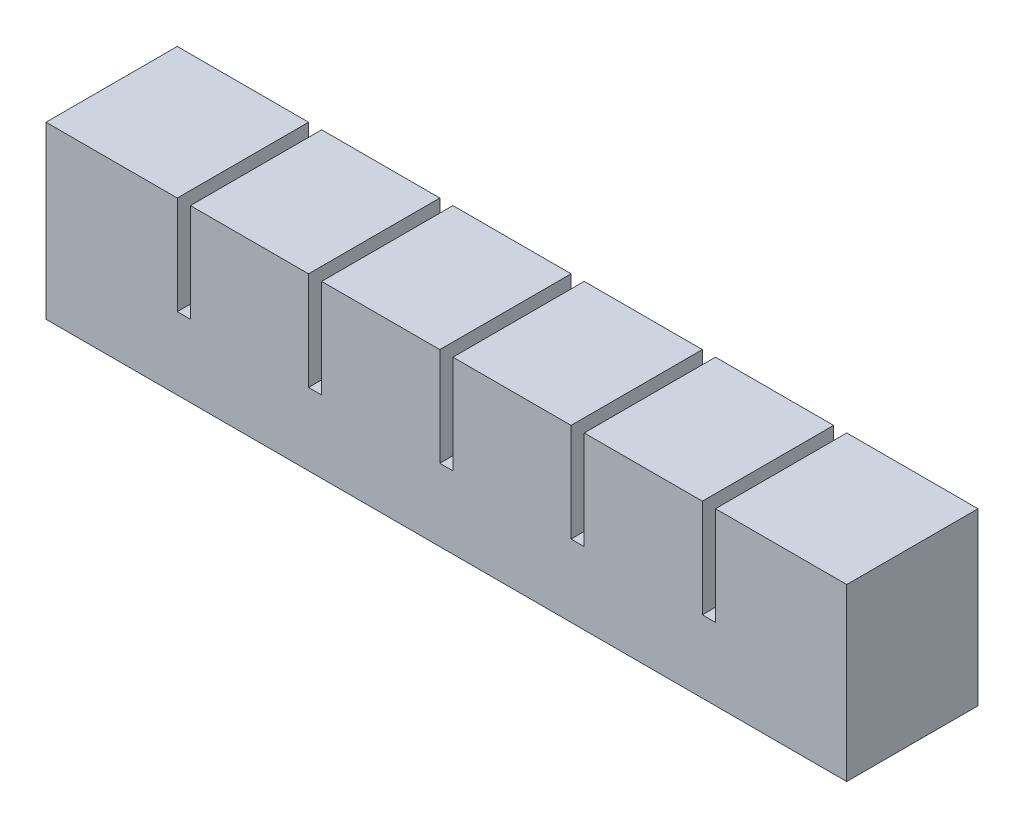
from build123d import *

# Parameters (mm, degrees)
SKETCH1_W           = 18
SKETCH1_H           = 20
BOSS_EXTRUDE1_DEPTH = 20
SKETCH2_W           = 6
SKETCH2_H           = 8
CUT_EXTRUDE1_DEPTH  = 14
SKETCH3_W           = 20
SKETCH3_H           = 5
BOSS_EXTRUDE2_DEPTH = 2
LPATTERN1_COUNT     = 6
LPATTERN1_PITCH     = 20
SKETCH4_W           = 20
SKETCH4_H           = 15
BOSS_EXTRUDE3_DEPTH = 2
SKETCH5_W           = 20
SKETCH5_H           = 20
BOSS_EXTRUDE4_DEPTH = 2
SKETCH7_W           = 106
SKETCH7_H           = 2
CUT_EXTRUDE2_DEPTH  = 2
SKETCH8_W           = 122
SKETCH8_H           = 20
BOSS_EXTRUDE5_DEPTH = 6


with BuildPart() as part:
    # Sketch1 → Boss-Extrude1 (new body)
    with BuildSketch(Plane.XY):
        with Locations((9, 10)):
            Rectangle(SKETCH1_W, SKETCH1_H)
    extrude(amount=BOSS_EXTRUDE1_DEPTH)

    # Sketch2 → Cut-Extrude1 (cut)
    with BuildSketch(Plane.XZ):
        with Locations((9, 10)):
            Rectangle(SKETCH2_W, SKETCH2_H)
    extrude(amount=-CUT_EXTRUDE1_DEPTH, mode=Mode.SUBTRACT)

    # Sketch3 → Boss-Extrude2 (add)
    with BuildSketch(Plane(origin=(18, 0, 0), x_dir=(0, 0, -1), z_dir=(1, 0, 0))):
        with Locations((-10, 2.5)):
            Rectangle(SKETCH3_W, SKETCH3_H)
    extrude(amount=BOSS_EXTRUDE2_DEPTH)


with BuildPart() as lpattern1_1:
    # LPattern1: pattern copy
    add(part.part.moved(Location(Vector(1, 0, 0) * (1 * LPATTERN1_PITCH))))


with BuildPart() as lpattern1_2:
    # LPattern1: pattern copy
    add(part.part.moved(Location(Vector(1, 0, 0) * (2 * LPATTERN1_PITCH))))


with BuildPart() as lpattern1_3:
    # LPattern1: pattern copy
    add(part.part.moved(Location(Vector(1, 0, 0) * (3 * LPATTERN1_PITCH))))


with BuildPart() as lpattern1_4:
    # LPattern1: pattern copy
    add(part.part.moved(Location(Vector(1, 0, 0) * (4 * LPATTERN1_PITCH))))


with BuildPart() as lpattern1_5:
    # LPattern1: pattern copy
    add(part.part.moved(Location(Vector(1, 0, 0) * (5 * LPATTERN1_PITCH))))

    # Sketch4 → Boss-Extrude3 (add)
    with BuildSketch(Plane(origin=(118, 0, 0), x_dir=(0, 0, -1), z_dir=(1, 0, 0))):
        with Locations((-10, 12.5)):
            Rectangle(SKETCH4_W, SKETCH4_H)
    extrude(amount=BOSS_EXTRUDE3_DEPTH)


with BuildPart() as part_1:
    add(part.part)

    # Sketch5 → Boss-Extrude4 (add)
    with BuildSketch(Plane.ZY):
        with Locations((10, 10)):
            Rectangle(SKETCH5_W, SKETCH5_H)
    extrude(amount=BOSS_EXTRUDE4_DEPTH)


with BuildPart() as lpattern1_1_1:
    add(lpattern1_1.part)

    # Combine1: union LPattern1_2, LPattern1_3, LPattern1_4, LPattern1_5, part
    add(lpattern1_2.part)
    add(lpattern1_3.part)
    add(lpattern1_4.part)
    add(lpattern1_5.part)
    add(part_1.part)

    # Sketch7 → Cut-Extrude2 (cut)
    with BuildSketch(Plane(origin=(0, 0, 0), x_dir=(-1, 0, 0), z_dir=(0, -1, 0))):
        with Locations((-59, -10)):
            Rectangle(SKETCH7_W, SKETCH7_H)
    extrude(amount=-CUT_EXTRUDE2_DEPTH, mode=Mode.SUBTRACT)

    # Sketch8 → Boss-Extrude5 (add)
    with BuildSketch(Plane(origin=(0, 0, 0), x_dir=(-1, 0, 0), z_dir=(0, -1, 0))):
        with Locations((-59, -10)):
            Rectangle(SKETCH8_W, SKETCH8_H)
    extrude(amount=BOSS_EXTRUDE5_DEPTH)


solid = lpattern1_1_1.part
